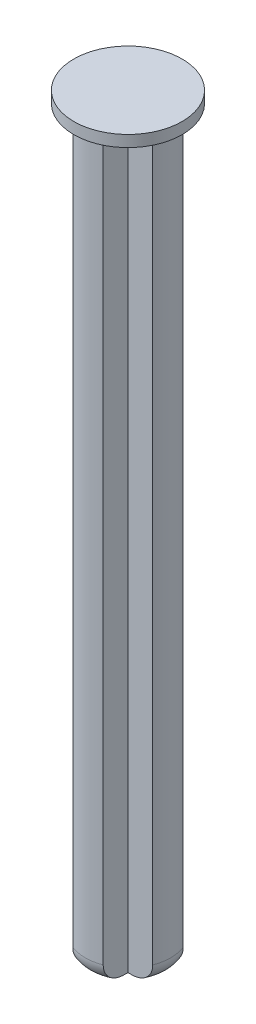
from build123d import *

# Parameters (mm, degrees)
BOSS_EXTRUDE1_DEPTH = 39.4
FILLET1_R           = 1
FILLET2_R           = 1
FILLET3_R           = 1
FILLET4_R           = 1
SKETCH3_R           = 2.85
BOSS_EXTRUDE2_DEPTH = 0.6


with BuildPart() as part:
    # Sketch1 → Boss-Extrude1 (new body)
    with BuildSketch(Plane(origin=(0, 0, 0), x_dir=(1, 0, 0), z_dir=(0, 1, 0))):
        with BuildLine():
            Line((-0.8, -0.8), (-0.8, -2.102974084))
            ThreePointArc((-0.8, -2.102974084), (0, -2.25), (0.8, -2.102974084))
            Line((0.8, -2.102974084), (0.8, -0.8))
            Line((0.8, -0.8), (2.102974084, -0.8))
            ThreePointArc((2.102974084, -0.8), (2.25, 0), (2.102974084, 0.8))
            Line((2.102974084, 0.8), (0.8, 0.8))
            Line((0.8, 0.8), (0.8, 2.102974084))
            ThreePointArc((0.8, 2.102974084), (0, 2.25), (-0.8, 2.102974084))
            Line((-0.8, 2.102974084), (-0.8, 0.8))
            Line((-0.8, 0.8), (-2.102974084, 0.8))
            ThreePointArc((-2.102974084, 0.8), (-2.25, 0), (-2.102974084, -0.8))
            Line((-2.102974084, -0.8), (-0.8, -0.8))
        make_face()
    extrude(amount=BOSS_EXTRUDE1_DEPTH)

    # Fillet1
    fillet1_edges = [part.edges().sort_by_distance(p)[0] for p in [
        (-2.25, 0, 0),
    ]]
    fillet(fillet1_edges, radius=FILLET1_R)

    # Fillet2
    fillet2_edges = [part.edges().sort_by_distance(p)[0] for p in [
        (0, 0, 2.25),
    ]]
    fillet(fillet2_edges, radius=FILLET2_R)

    # Fillet3
    fillet3_edges = [part.edges().sort_by_distance(p)[0] for p in [
        (2.25, 0, 0),
    ]]
    fillet(fillet3_edges, radius=FILLET3_R)

    # Fillet4
    fillet4_edges = [part.edges().sort_by_distance(p)[0] for p in [
        (0, 0, -2.25),
    ]]
    fillet(fillet4_edges, radius=FILLET4_R)

    # Sketch3 → Boss-Extrude2 (add)
    with BuildSketch(Plane(origin=(0, 39.4, 0), x_dir=(1, 0, 0), z_dir=(0, 1, 0))):
        with Locations(Location((0, 0, 0), (0, 0, 270))):
            Circle(SKETCH3_R)
    extrude(amount=-BOSS_EXTRUDE2_DEPTH)


solid = part.part
